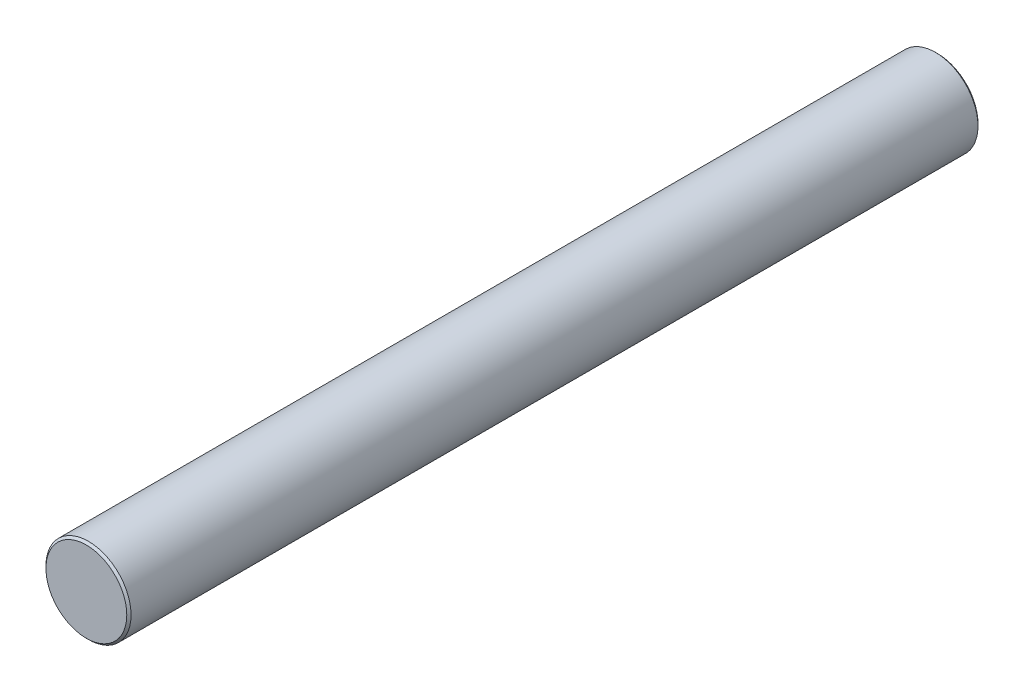
from build123d import *

# Parameters (mm, degrees)
SKETCH1_R           = 5.08
BOSS_EXTRUDE1_DEPTH = 50.8
CHAMFER1_SIZE       = 0.254


with BuildPart() as part:
    # Sketch1 → Boss-Extrude1 (new body, symmetric)
    with BuildSketch(Plane.XY):
        Circle(SKETCH1_R)
    extrude(amount=BOSS_EXTRUDE1_DEPTH, both=True)

    # Chamfer1
    chamfer1_edges = [part.edges().sort_by_distance(p)[0] for p in [
        (-5.08, 0, -50.8),
        (-5.08, 0, 50.8),
    ]]
    chamfer(chamfer1_edges, length=CHAMFER1_SIZE)


solid = part.part
